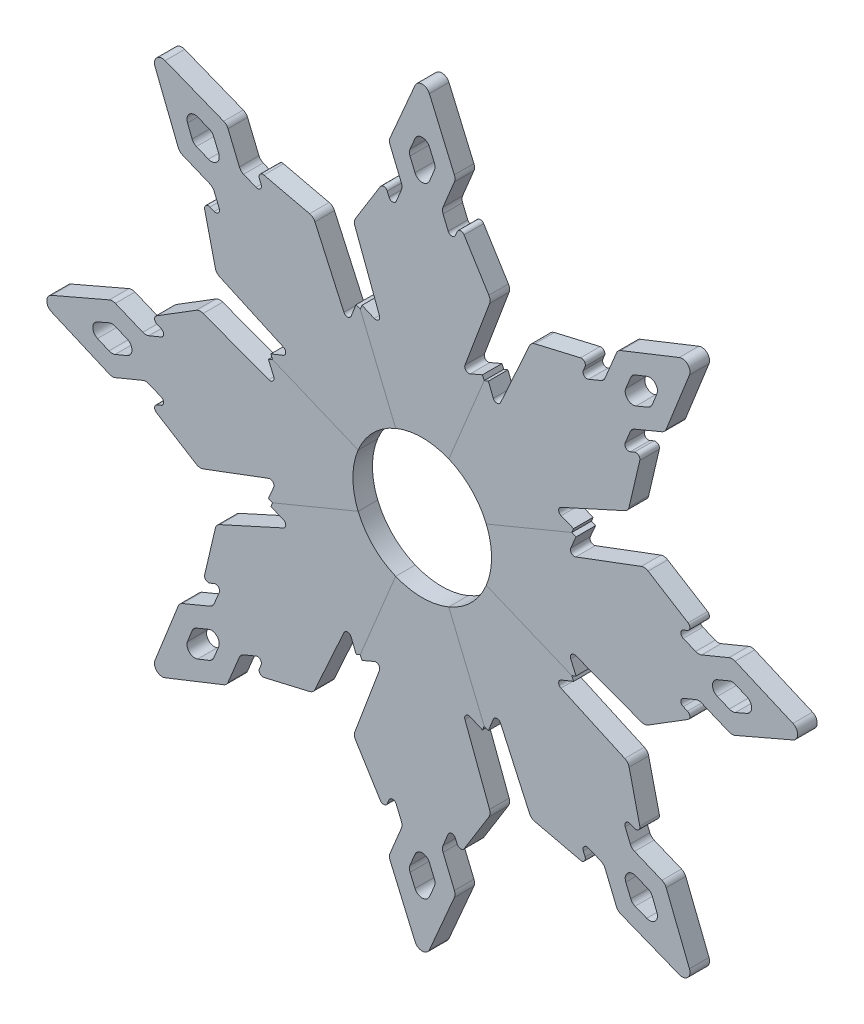
from build123d import *

# Parameters (mm, degrees)
EXTRUDE_1_DEPTH   = 5
CIRPATTERN1_COUNT = 8


with BuildPart() as part:
    # Эскиз1 → Бобышка-Вытянуть1 (new body)
    with BuildSketch(Plane.XY):
        with BuildLine():
            Line((-8.034847802, 1.66966916), (-17.096495486, 23.546421897))
            Line((-17.096495486, 23.546421897), (-16.64056892, 24.602822277))
            Line((-16.64056892, 24.602822277), (-13.50951063, 23.25150446))
            ThreePointArc((-13.50951063, 23.25150446), (-12.42356132, 23.445543517), (-12.176925884, 24.520768155))
            Line((-12.176925884, 24.520768155), (-18.460897336, 41.278025359))
            ThreePointArc((-18.460897336, 41.278025359), (-18.578542401, 42.176975813), (-18.287203857, 43.035506031))
            Line((-18.287203857, 43.035506031), (-11.955801124, 53.229295288))
            ThreePointArc((-11.955801124, 53.229295288), (-11.0248622, 53.698355293), (-10.182439153, 53.084361826))
            Line((-10.182439153, 53.084361826), (-9.737089987, 52.00919383))
            ThreePointArc((-9.737089987, 52.00919383), (-8.813210455, 51.391877262), (-7.889330922, 52.00919383))
            Line((-7.889330922, 52.00919383), (-6.57738407, 55.176513714))
            ThreePointArc((-6.57738407, 55.176513714), (-6.425143135, 55.941880578), (-6.57738407, 56.707247443))
            Line((-6.57738407, 56.707247443), (-9.477173027, 63.707957272))
            ThreePointArc((-9.477173027, 63.707957272), (-9.629359676, 64.488059883), (-9.465694469, 65.265835274))
            Line((-9.465694469, 65.265835274), (-3.088887767, 80.041155514))
            ThreePointArc((-3.088887767, 80.041155514), (-1.252607261, 81.248644378), (0.583673246, 80.041155514))
            Line((0.583673246, 80.041155514), (6.960479947, 65.265835274))
            ThreePointArc((6.960479947, 65.265835274), (7.124145155, 64.488059883), (6.971958506, 63.707957272))
            Line((6.971958506, 63.707957272), (4.072169549, 56.707247443))
            ThreePointArc((4.072169549, 56.707247443), (3.919928614, 55.941880578), (4.072169549, 55.176513714))
            Line((4.072169549, 55.176513714), (5.384116401, 52.00919383))
            ThreePointArc((5.384116401, 52.00919383), (6.307995933, 51.391877262), (7.231875466, 52.00919383))
            Line((7.231875466, 52.00919383), (7.677224632, 53.084361826))
            ThreePointArc((7.677224632, 53.084361826), (8.519647679, 53.698355293), (9.450586602, 53.229295288))
            Line((9.450586602, 53.229295288), (15.781989335, 43.035506031))
            ThreePointArc((15.781989335, 43.035506031), (16.073327879, 42.176975813), (15.955682814, 41.278025359))
            Line((15.955682814, 41.278025359), (9.671711363, 24.520768155))
            ThreePointArc((9.671711363, 24.520768155), (9.918346798, 23.445543517), (11.004296109, 23.25150446))
            Line((11.004296109, 23.25150446), (14.135354399, 24.602822277))
            Line((14.135354399, 24.602822277), (14.591280965, 23.546421897))
            Line((14.591280965, 23.546421897), (5.52963328, 1.66966916))
            ThreePointArc((5.52963328, 1.66966916), (-1.252607261, 3.018740682), (-8.034847802, 1.66966916))
        make_face()
        with BuildLine():
            Line((-3.088887767, 68.27966401), (-4.357617875, 65.339964798))
            ThreePointArc((-4.357617875, 65.339964798), (-4.521283082, 64.562189407), (-4.369096433, 63.782086796))
            Line((-4.369096433, 63.782086796), (-3.100366326, 60.719101364))
            ThreePointArc((-3.100366326, 60.719101364), (-1.252607261, 59.484468229), (0.595151804, 60.719101364))
            Line((0.595151804, 60.719101364), (1.863881912, 63.782086796))
            ThreePointArc((1.863881912, 63.782086796), (2.016068561, 64.562189407), (1.852403353, 65.339964798))
            Line((1.852403353, 65.339964798), (0.583673246, 68.27966401))
            ThreePointArc((0.583673246, 68.27966401), (-1.252607261, 69.487152873), (-3.088887767, 68.27966401))
        make_face(mode=Mode.SUBTRACT)
    extrude(amount=EXTRUDE_1_DEPTH)


with BuildPart() as cirpattern1_1:
    # CirPattern1: pattern copy
    add(part.part.rotate(Axis((-1.252607261, -14.704107938, 0), (0, 0, 1)), 1 * 360 / CIRPATTERN1_COUNT))


with BuildPart() as cirpattern1_2:
    # CirPattern1: pattern copy
    add(part.part.rotate(Axis((-1.252607261, -14.704107938, 0), (0, 0, 1)), 2 * 360 / CIRPATTERN1_COUNT))


with BuildPart() as cirpattern1_3:
    # CirPattern1: pattern copy
    add(part.part.rotate(Axis((-1.252607261, -14.704107938, 0), (0, 0, 1)), 3 * 360 / CIRPATTERN1_COUNT))


with BuildPart() as cirpattern1_4:
    # CirPattern1: pattern copy
    add(part.part.rotate(Axis((-1.252607261, -14.704107938, 0), (0, 0, 1)), 4 * 360 / CIRPATTERN1_COUNT))


with BuildPart() as cirpattern1_5:
    # CirPattern1: pattern copy
    add(part.part.rotate(Axis((-1.252607261, -14.704107938, 0), (0, 0, 1)), 5 * 360 / CIRPATTERN1_COUNT))


with BuildPart() as cirpattern1_6:
    # CirPattern1: pattern copy
    add(part.part.rotate(Axis((-1.252607261, -14.704107938, 0), (0, 0, 1)), 6 * 360 / CIRPATTERN1_COUNT))


with BuildPart() as cirpattern1_7:
    # CirPattern1: pattern copy
    add(part.part.rotate(Axis((-1.252607261, -14.704107938, 0), (0, 0, 1)), 7 * 360 / CIRPATTERN1_COUNT))


solid = Compound([part.part, cirpattern1_1.part, cirpattern1_2.part, cirpattern1_3.part, cirpattern1_4.part, cirpattern1_5.part, cirpattern1_6.part, cirpattern1_7.part])
